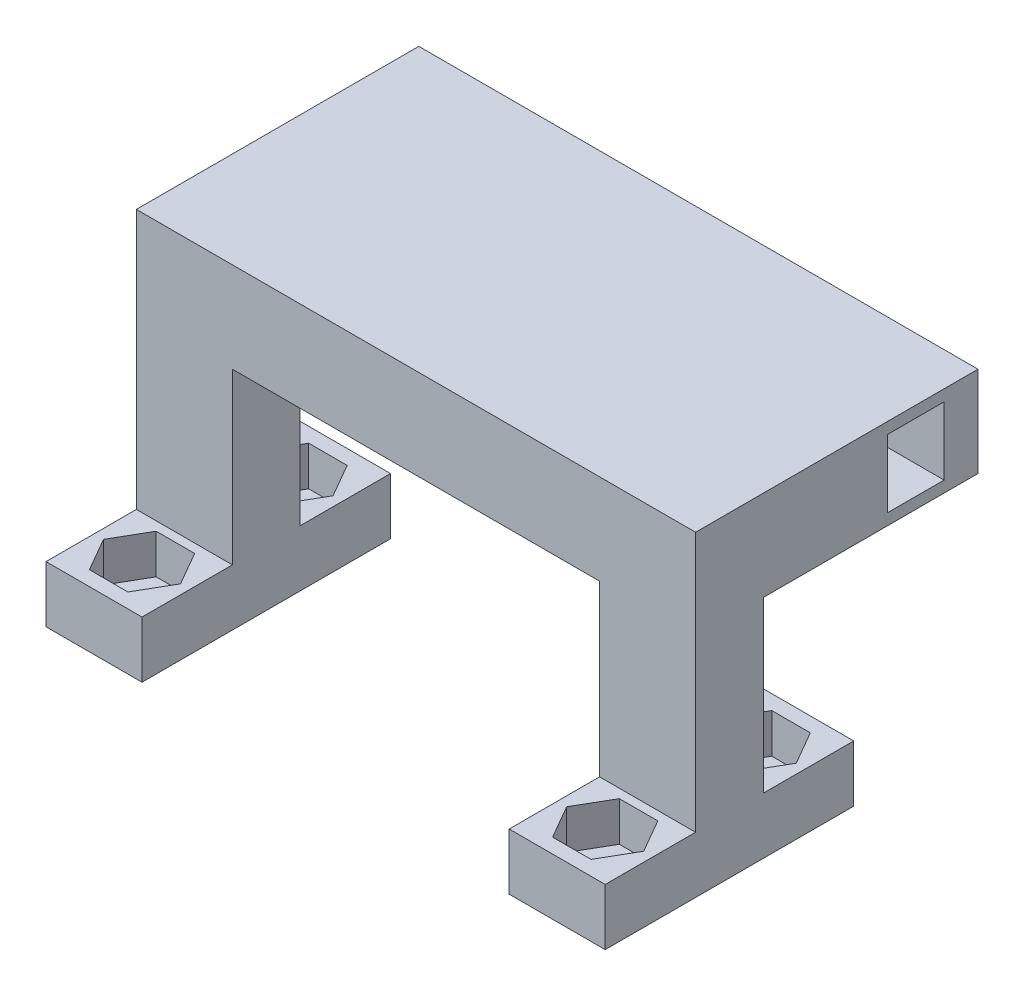
from build123d import *

# Parameters (mm, degrees)
SKETCH1_W            = 8.5
SKETCH1_H            = 22
BOSS_EXTRUDE1_DEPTH  = 5
CUT_EXTRUDE1_DEPTH   = 3.5
SKETCH3_R            = 1.5
CUT_EXTRUDE2_DEPTH   = 1.5
SKETCH4_W            = 8.5
SKETCH4_H            = 6
BOSS_EXTRUDE2_DEPTH  = 23
SKETCH7_W            = 8.5
SKETCH7_H            = 22
BOSS_EXTRUDE4_DEPTH  = 5
CUT_EXTRUDE3_DEPTH   = 3.5
SKETCH9_R            = 1.5
CUT_EXTRUDE4_DEPTH   = 3.5
SKETCH10_W           = 8.5
SKETCH10_H           = 6
BOSS_EXTRUDE5_DEPTH  = 23
SKETCH6_W            = 6
SKETCH6_H            = 8
BOSS_EXTRUDE6_DEPTH  = 30.5
SKETCH11_W           = 47.5
SKETCH11_H           = 8
BOSS_EXTRUDE7_DEPTH  = 13.5
SKETCH12_W           = 47.5
SKETCH12_H           = 8
BOSS_EXTRUDE8_DEPTH  = 5.5
SKETCH13_W           = 5
SKETCH13_H           = 6
CUT_EXTRUDE5_DEPTH   = 15
SKETCH14_W           = 5
SKETCH14_H           = 6
CUT_EXTRUDE6_DEPTH   = 4
SKETCH15_W           = 5
SKETCH15_H           = 6
CUT_EXTRUDE7_DEPTH   = 15
SKETCH16_W           = 5
SKETCH16_H           = 6
CUT_EXTRUDE8_DEPTH   = 4
SKETCH17_W           = 5
SKETCH17_H           = 6
BOSS_EXTRUDE9_DEPTH  = 2
SKETCH18_W           = 10.5
SKETCH18_H           = 8
BOSS_EXTRUDE10_DEPTH = 5
CUT_EXTRUDE9_DEPTH   = 2
SKETCH23_R           = 1.5
CUT_EXTRUDE10_DEPTH  = 3.5
CUT_EXTRUDE11_REACH  = 58.867
SKETCH24_R           = 1.5
SKETCH25_W           = 5
SKETCH25_H           = 6
BOSS_EXTRUDE11_DEPTH = 2


with BuildPart() as part:
    # Sketch1 → Boss-Extrude1 (new body)
    with BuildSketch(Plane(origin=(0, 0, 0), x_dir=(1, 0, 0), z_dir=(0, 1, 0))):
        Rectangle(SKETCH1_W, SKETCH1_H)
    extrude(amount=BOSS_EXTRUDE1_DEPTH)

    # Sketch2 → Cut-Extrude1 (cut)
    with BuildSketch(Plane(origin=(0, 5, 0), x_dir=(1, 0, 0), z_dir=(0, 1, 0))):
        Polygon((-1.705, 9.703146627), (-3.41, 6.75), (-1.705, 3.796853373), (1.705, 3.796853373), (3.41, 6.75), (1.705, 9.703146627), align=None)
        Polygon((1.705, -9.703146627), (-1.705, -9.703146627), (-3.41, -6.75), (-1.705, -3.796853373), (1.705, -3.796853373), (3.41, -6.75), align=None)
    extrude(amount=-CUT_EXTRUDE1_DEPTH, mode=Mode.SUBTRACT)

    # Sketch3 → Cut-Extrude2 (cut)
    with BuildSketch(Plane(origin=(0, 1.5, 0), x_dir=(1, 0, 0), z_dir=(0, 1, 0))):
        with Locations(Location((0, 6.75, 0), (0, 0, 270))):
            Circle(SKETCH3_R)
        with Locations(Location((0, -6.75, 0), (0, 0, 270))):
            Circle(SKETCH3_R)
        with Locations((39, 6.75)):
            Circle(SKETCH3_R)
        with Locations((39, -6.75)):
            Circle(SKETCH3_R)
    extrude(amount=-CUT_EXTRUDE2_DEPTH, mode=Mode.SUBTRACT)

    # Sketch4 → Boss-Extrude2 (add)
    with BuildSketch(Plane(origin=(0, 5, 0), x_dir=(1, 0, 0), z_dir=(0, 1, 0))):
        Rectangle(SKETCH4_W, SKETCH4_H)
    extrude(amount=BOSS_EXTRUDE2_DEPTH)



with BuildPart() as body_2:
    # Sketch7 → Boss-Extrude4 (new body)
    with BuildSketch(Plane(origin=(0, 0, 0), x_dir=(1, 0, 0), z_dir=(0, 1, 0))):
        with Locations((39, 0)):
            Rectangle(SKETCH7_W, SKETCH7_H)
    extrude(amount=BOSS_EXTRUDE4_DEPTH)

    # Sketch8 → Cut-Extrude3 (cut)
    with BuildSketch(Plane(origin=(0, 5, 0), x_dir=(1, 0, 0), z_dir=(0, 1, 0))):
        Polygon((40.705, 9.703146627), (37.295, 9.703146627), (35.59, 6.75), (37.295, 3.796853373), (40.705, 3.796853373), (42.41, 6.75), align=None)
        Polygon((40.705, -3.796853373), (37.295, -3.796853373), (35.59, -6.75), (37.295, -9.703146627), (40.705, -9.703146627), (42.41, -6.75), align=None)
    extrude(amount=-CUT_EXTRUDE3_DEPTH, mode=Mode.SUBTRACT)

    # Sketch9 → Cut-Extrude4 (cut)
    with BuildSketch(Plane(origin=(0, 1.5, 0), x_dir=(1, 0, 0), z_dir=(0, 1, 0))):
        with Locations(Location((39, 6.75, 0), (0, 0, 270))):
            Circle(SKETCH9_R)
        with Locations(Location((39, -6.75, 0), (0, 0, 270))):
            Circle(SKETCH9_R)
    extrude(amount=-CUT_EXTRUDE4_DEPTH, mode=Mode.SUBTRACT)

    # Sketch10 → Boss-Extrude5 (add)
    with BuildSketch(Plane(origin=(0, 5, 0), x_dir=(1, 0, 0), z_dir=(0, 1, 0))):
        with Locations((39, 0)):
            Rectangle(SKETCH10_W, SKETCH10_H)
    extrude(amount=BOSS_EXTRUDE5_DEPTH)


with BuildPart() as part_1:
    add(part.part)

    add(body_2.part)  # Boss-Extrude6 merges body 2
    # Sketch6 → Boss-Extrude6 (add)
    with BuildSketch(Plane(origin=(4.25, 0, 0), x_dir=(0, 0, -1), z_dir=(1, 0, 0))):
        with Locations((0, 24)):
            Rectangle(SKETCH6_W, SKETCH6_H)
    extrude(amount=BOSS_EXTRUDE6_DEPTH)

    # Sketch11 → Boss-Extrude7 (add)
    with BuildSketch(Plane(origin=(0, 0, -3), x_dir=(-1, 0, 0), z_dir=(0, 0, -1))):
        with Locations((-19.5, 24)):
            Rectangle(SKETCH11_W, SKETCH11_H)
    extrude(amount=BOSS_EXTRUDE7_DEPTH)

    # Sketch12 → Boss-Extrude8 (add)
    with BuildSketch(Plane(origin=(0, 0, -16.5), x_dir=(-1, 0, 0), z_dir=(0, 0, -1))):
        with Locations((-19.5, 24)):
            Rectangle(SKETCH12_W, SKETCH12_H)
    extrude(amount=BOSS_EXTRUDE8_DEPTH)

    # Sketch13 → Cut-Extrude5 (cut)
    with BuildSketch(Plane.ZY.offset(4.25)):
        with Locations((-16.5, 24)):
            Rectangle(SKETCH13_W, SKETCH13_H)
    extrude(amount=-CUT_EXTRUDE5_DEPTH, mode=Mode.SUBTRACT)

    # Sketch14 → Cut-Extrude6 (cut)
    with BuildSketch(Plane(origin=(0, 0, -22), x_dir=(-1, 0, 0), z_dir=(0, 0, -1))):
        with Locations((-8.25, 24)):
            Rectangle(SKETCH14_W, SKETCH14_H)
    extrude(amount=-CUT_EXTRUDE6_DEPTH, mode=Mode.SUBTRACT)

    # Sketch15 → Cut-Extrude7 (cut)
    with BuildSketch(Plane(origin=(43.25, 0, 0), x_dir=(0, 0, -1), z_dir=(1, 0, 0))):
        with Locations((16.5, 24)):
            Rectangle(SKETCH15_W, SKETCH15_H)
    extrude(amount=-CUT_EXTRUDE7_DEPTH, mode=Mode.SUBTRACT)

    # Sketch16 → Cut-Extrude8 (cut)
    with BuildSketch(Plane(origin=(0, 0, -22), x_dir=(-1, 0, 0), z_dir=(0, 0, -1))):
        with Locations((-32.75, 24)):
            Rectangle(SKETCH16_W, SKETCH16_H)
    extrude(amount=-CUT_EXTRUDE8_DEPTH, mode=Mode.SUBTRACT)

    # Sketch17 → Boss-Extrude9 (add)
    with BuildSketch(Plane(origin=(43.25, 0, 0), x_dir=(0, 0, -1), z_dir=(1, 0, 0))):
        Polygon((-3, 5), (-11, 5), (-11, 0), (11, 0), (11, 5), (3, 5), (3, 20), (22, 20), (22, 28), (-3, 28), align=None)
        with Locations((16.5, 24)):
            Rectangle(SKETCH17_W, SKETCH17_H, mode=Mode.SUBTRACT)
    extrude(amount=BOSS_EXTRUDE9_DEPTH)

    # Sketch18 → Boss-Extrude10 (add)
    with BuildSketch(Plane(origin=(0, 5, 0), x_dir=(1, 0, 0), z_dir=(0, 1, 0))):
        with Locations((40, -7)):
            Rectangle(SKETCH18_W, SKETCH18_H)
        with Locations((40, 7)):
            Rectangle(SKETCH18_W, SKETCH18_H)
    extrude(amount=-BOSS_EXTRUDE10_DEPTH)

    # Sketch20 → Cut-Extrude9 (cut)
    with BuildSketch(Plane.ZY.offset(-34.75)):
        Polygon((-3, 5), (-11, 5), (-11, 0), (11, 0), (11, 5), (3, 5), (3, 20), (-3, 20), align=None)
    extrude(amount=-CUT_EXTRUDE9_DEPTH, mode=Mode.SUBTRACT)

    # Sketch23 → Cut-Extrude10 (cut)
    with BuildSketch(Plane(origin=(0, 5, 0), x_dir=(1, 0, 0), z_dir=(0, 1, 0))):
        Polygon((42.705, 9.703146627), (39.295, 9.703146627), (37.59, 6.75), (39.295, 3.796853373), (42.705, 3.796853373), (44.41, 6.75), align=None)
        with Locations((41, 6.75)):
            Circle(SKETCH23_R, mode=Mode.SUBTRACT)
        with Locations((41, 6.75)):
            Circle(SKETCH23_R)
        Polygon((39.295, -9.703146627), (42.705, -9.703146627), (44.41, -6.75), (42.705, -3.796853373), (39.295, -3.796853373), (37.59, -6.75), align=None)
        with Locations((41, -6.75)):
            Circle(SKETCH23_R, mode=Mode.SUBTRACT)
        with Locations((41, -6.75)):
            Circle(SKETCH23_R)
    extrude(amount=-CUT_EXTRUDE10_DEPTH, mode=Mode.SUBTRACT)

    # Sketch24 → Cut-Extrude11 (cut, up to next)
    with BuildSketch(Plane(origin=(0, 1.5, 0), x_dir=(1, 0, 0), z_dir=(0, 1, 0)), mode=Mode.PRIVATE) as cut_extrude11_sk1:
        with Locations(Location((41, -6.75, 0), (0, 0, 270))):
            Circle(SKETCH24_R)
    cut_extrude11_tool1 = extrude(cut_extrude11_sk1.sketch, amount=-CUT_EXTRUDE11_REACH, mode=Mode.PRIVATE) & part_1.part
    # Sketch24 → Cut-Extrude11 (cut, up to next)
    with BuildSketch(Plane(origin=(0, 1.5, 0), x_dir=(1, 0, 0), z_dir=(0, 1, 0)), mode=Mode.PRIVATE) as cut_extrude11_sk2:
        with Locations(Location((41, 6.75, 0), (0, 0, 270))):
            Circle(SKETCH24_R)
    cut_extrude11_tool2 = extrude(cut_extrude11_sk2.sketch, amount=-CUT_EXTRUDE11_REACH, mode=Mode.PRIVATE) & part_1.part
    add(cut_extrude11_tool1.solids().sort_by_distance((41, 1.5, 6.75))[0], mode=Mode.SUBTRACT)
    add(cut_extrude11_tool2.solids().sort_by_distance((41, 1.5, -6.75))[0], mode=Mode.SUBTRACT)

    # Sketch25 → Boss-Extrude11 (add)
    with BuildSketch(Plane(origin=(28.25, 0, 0), x_dir=(0, 0, -1), z_dir=(1, 0, 0))):
        with Locations((16.5, 24)):
            Rectangle(SKETCH25_W, SKETCH25_H)
    extrude(amount=BOSS_EXTRUDE11_DEPTH)


solid = part_1.part
